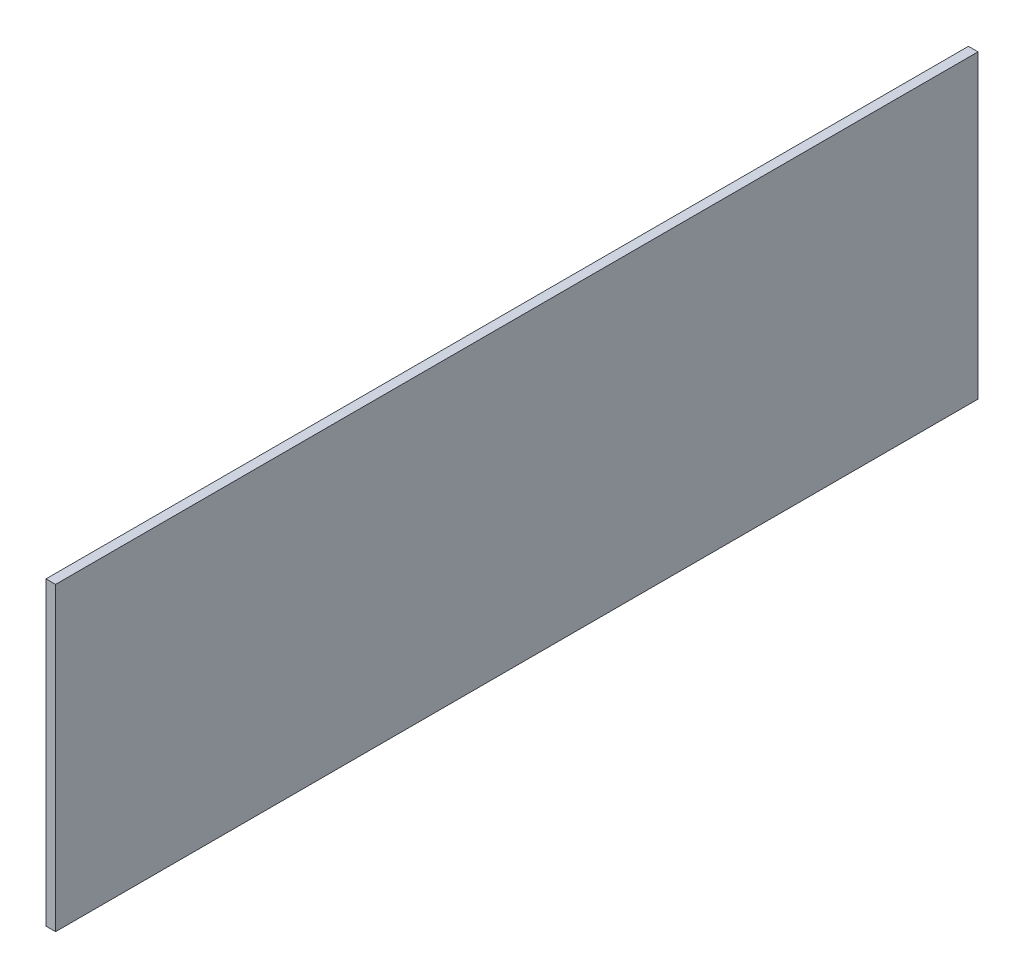
from build123d import *

# Parameters (mm, degrees)
SKETCH1_W           = 292.1
SKETCH1_H           = 95.25
BOSS_EXTRUDE1_DEPTH = 3.03


with BuildPart() as part:
    # Sketch1 → Boss-Extrude1 (new body)
    with BuildSketch(Plane(origin=(0, 0, 0), x_dir=(0, 0, -1), z_dir=(1, 0, 0))):
        with Locations((-41.275, -13.335)):
            Rectangle(SKETCH1_W, SKETCH1_H)
    extrude(amount=BOSS_EXTRUDE1_DEPTH)


solid = part.part
